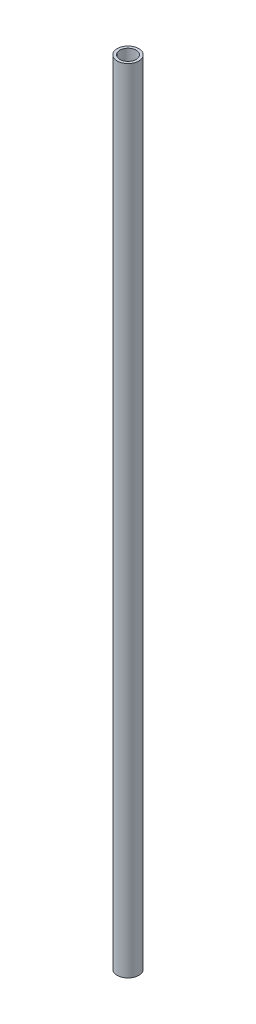
from build123d import *

# Parameters (mm, degrees)
SKETCH1_R           = 2
SKETCH1_R_2         = 1.5
BOSS_EXTRUDE1_DEPTH = 73.5


with BuildPart() as part:
    # Sketch1 → Boss-Extrude1 (new body, symmetric)
    with BuildSketch(Plane(origin=(0, 0, 0), x_dir=(1, 0, 0), z_dir=(0, 1, 0))):
        Circle(SKETCH1_R)
        Circle(SKETCH1_R_2, mode=Mode.SUBTRACT)
    extrude(amount=BOSS_EXTRUDE1_DEPTH, both=True)


solid = part.part
